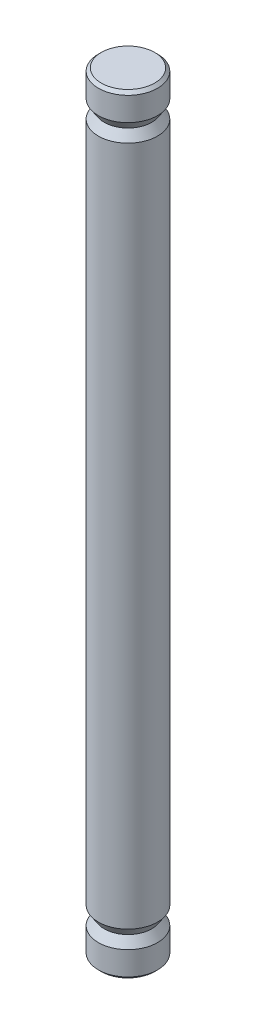
from build123d import *

# Parameters (mm, degrees)
ESQUISSE1_R        = 2.5
BOSS_EXTRU_1_DEPTH = 65
CHANFREIN1_SIZE    = 0.25


with BuildPart() as part:
    # Esquisse1 → Boss.-Extru.1 (new body)
    with BuildSketch(Plane(origin=(0, 0, 0), x_dir=(1, 0, 0), z_dir=(0, 1, 0))):
        Circle(ESQUISSE1_R)
    extrude(amount=BOSS_EXTRU_1_DEPTH)

    # Chanfrein1
    chanfrein1_edges = [part.edges().sort_by_distance(p)[0] for p in [
        (-2.5, 0, 0),
        (-2.5, 65, 0),
    ]]
    chamfer(chanfrein1_edges, length=CHANFREIN1_SIZE)

    # Esquisse2 → Enlèvement de matière-Révolution1 (revolve, cut)
    with BuildSketch(Plane.XY):
        Polygon((2.5, 62.75), (2, 62), (2.5, 61.25), align=None)
        Polygon((2, 3), (2.5, 3.75), (2.5, 2.25), align=None)
    revolve(axis=Axis((0, 64.75, 0), (0, -1, 0)), mode=Mode.SUBTRACT)


solid = part.part
